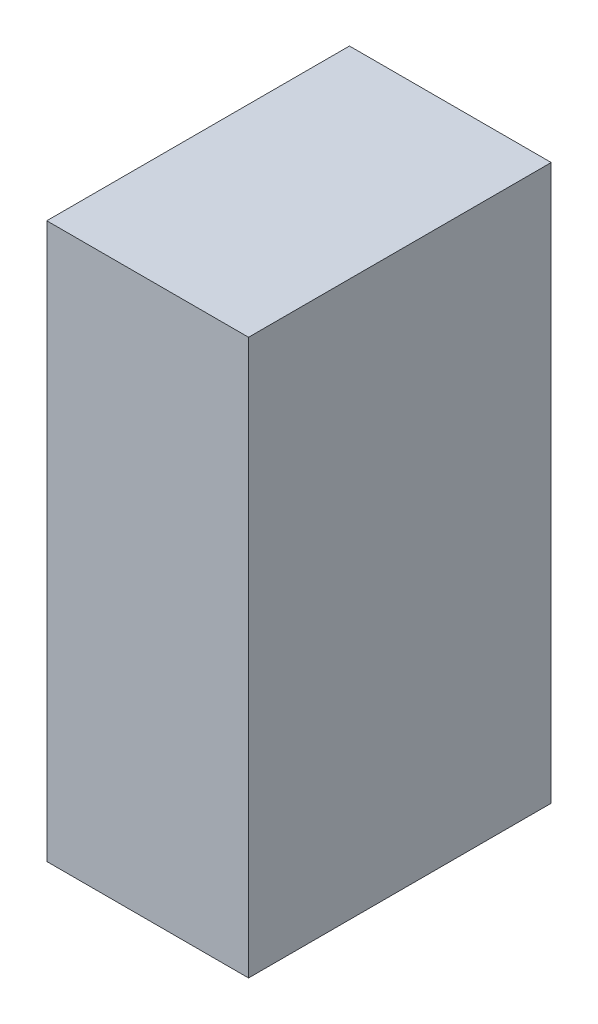
from build123d import *

# Parameters (mm, degrees)
SCHIZZO1_W                   = 40
SCHIZZO1_H                   = 60
ESTRUSIONE_ESTRUSIONE1_DEPTH = 110


with BuildPart() as part:
    # Schizzo1 → Estrusione-Estrusione1 (new body)
    with BuildSketch(Plane(origin=(0, 0, 0), x_dir=(1, 0, 0), z_dir=(0, 1, 0))):
        Rectangle(SCHIZZO1_W, SCHIZZO1_H)
    extrude(amount=ESTRUSIONE_ESTRUSIONE1_DEPTH)


solid = part.part
